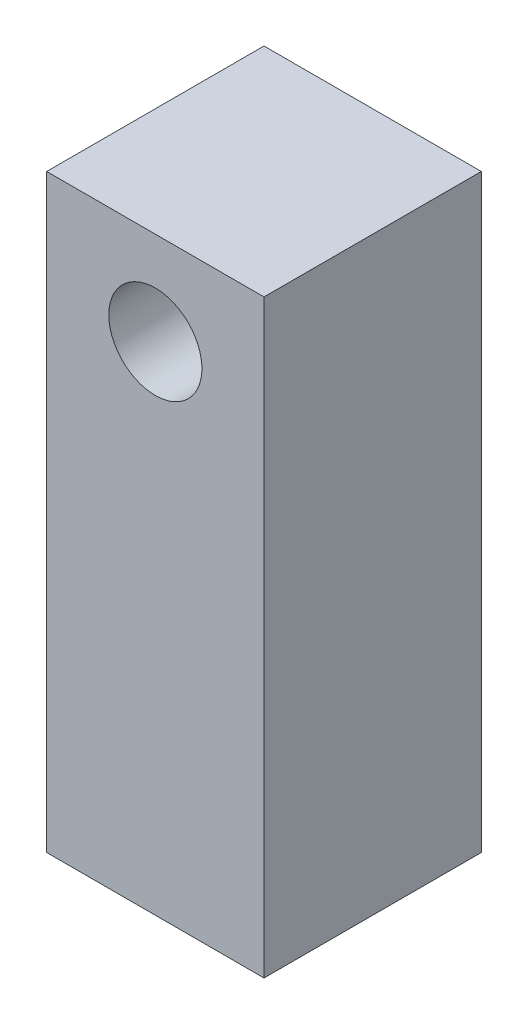
from build123d import *

# Parameters (mm, degrees)
SKETCH1_W                       = 7
SKETCH1_H                       = 7
SKETCH1_R                       = 2
BOSS_EXTRUDE1_DEPTH             = 13
BOSS_EXTRUDE2_REACH             = 5.5
SKETCH2_W                       = 7
SKETCH2_H                       = 6
SKETCH2_R                       = 1.5
BOSS_EXTRUDE2_DIRECTION_2_REACH = 5.5


with BuildPart() as part:
    # Sketch1 → Boss-Extrude1 (new body)
    with BuildSketch(Plane(origin=(0, 0, 0), x_dir=(1, 0, 0), z_dir=(0, 1, 0))):
        Rectangle(SKETCH1_W, SKETCH1_H)
        Circle(SKETCH1_R, mode=Mode.SUBTRACT)
    extrude(amount=BOSS_EXTRUDE1_DEPTH)

    # Boss-Extrude2: up to this face of the body (flat: up to its plane)
    boss_extrude2_end = Plane(part.part.faces().sort_by_distance((0, 6.5, 3.5))[0])
    # Sketch2 → Boss-Extrude2 (add, up to the picked face)
    with BuildSketch(Plane.XY, mode=Mode.PRIVATE) as boss_extrude2_sk1:
        with Locations((0, 16)):
            Rectangle(SKETCH2_W, SKETCH2_H)
        with Locations((0, 16)):
            Circle(SKETCH2_R, mode=Mode.SUBTRACT)
    boss_extrude2_tool1 = split(extrude(boss_extrude2_sk1.sketch, amount=BOSS_EXTRUDE2_REACH, mode=Mode.PRIVATE), bisect_by=boss_extrude2_end, keep=Keep.BOTH, mode=Mode.PRIVATE)
    add(boss_extrude2_tool1.solids().sort_by_distance((0, 18.907805, 0))[0])

    # Boss-Extrude2 direction 2: up to this face of the body (flat: up to its plane)
    boss_extrude2_direction_2_end = Plane(part.part.faces().sort_by_distance((0, 6.5, -3.5))[0])
    # Sketch2 → Boss-Extrude2 direction 2 (add, up to the picked face)
    with BuildSketch(Plane.XY, mode=Mode.PRIVATE) as boss_extrude2_direction_2_sk1:
        with Locations((0, 16)):
            Rectangle(SKETCH2_W, SKETCH2_H)
        with Locations((0, 16)):
            Circle(SKETCH2_R, mode=Mode.SUBTRACT)
    boss_extrude2_direction_2_tool1 = split(extrude(boss_extrude2_direction_2_sk1.sketch, amount=-BOSS_EXTRUDE2_DIRECTION_2_REACH, mode=Mode.PRIVATE), bisect_by=boss_extrude2_direction_2_end, keep=Keep.BOTH, mode=Mode.PRIVATE)
    add(boss_extrude2_direction_2_tool1.solids().sort_by_distance((0, 18.907805, 0))[0])


solid = part.part
